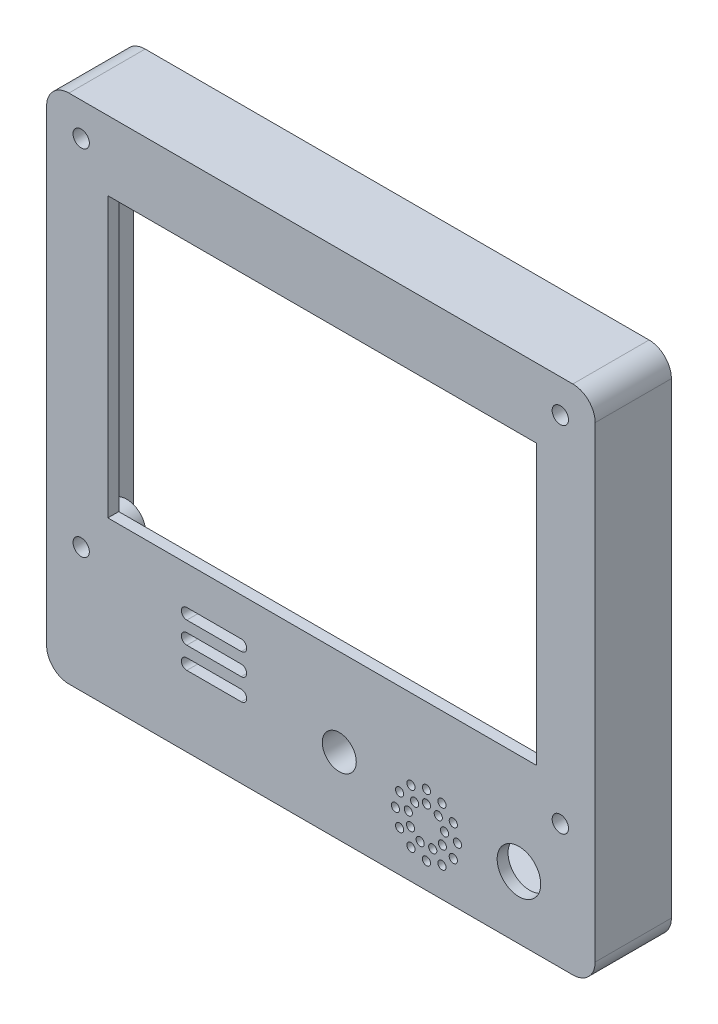
from build123d import *

# Parameters (mm, degrees)
SKETCH1_W           = 100.75
SKETCH1_H           = 94
BOSS_EXTRUDE1_DEPTH = 14
SHELL1_T            = -2
SKETCH2_R           = 3.5
SKETCH2_R_2         = 4
BOSS_EXTRUDE2_DEPTH = 6.3
SKETCH3_R           = 1.5
SKETCH3_R_2         = 4
SKETCH3_R_3         = 3.125
SKETCH3_R_4         = 0.75
SKETCH3_W           = 78.75
SKETCH3_H           = 51.25
CUT_EXTRUDE1_DEPTH  = 15
FILLET1_R           = 4.1


with BuildPart() as part:
    # Sketch1 → Boss-Extrude1 (new body)
    with BuildSketch(Plane.XY):
        Rectangle(SKETCH1_W, SKETCH1_H)
    extrude(amount=BOSS_EXTRUDE1_DEPTH)

    # Shell1
    shell1_openings = [part.faces().sort_by_distance(p)[0] for p in [
        (0, 0, 0),
    ]]
    offset(amount=SHELL1_T, openings=shell1_openings, kind=Kind.INTERSECTION)

    # Sketch2 → Boss-Extrude2 (add)
    with BuildSketch(Plane(origin=(0, 0, 12), x_dir=(-1, 0, 0), z_dir=(0, 0, -1))):
        with Locations((-43.975, 40.9)):
            Circle(SKETCH2_R)
        with Locations((-43.975, -24.1)):
            Circle(SKETCH2_R)
        with Locations((43.975, 40.9)):
            Circle(SKETCH2_R)
        with Locations((43.975, -24.1)):
            Circle(SKETCH2_R)
        with Locations((-3.375, -33)):
            Circle(SKETCH2_R_2)
    extrude(amount=BOSS_EXTRUDE2_DEPTH)

    # Sketch3 → Cut-Extrude1 (cut, through all)
    with BuildSketch(Plane.XY.offset(14)):
        with Locations((-44.025, 40.9)):
            Circle(SKETCH3_R)
        with Locations((43.975, 40.9)):
            Circle(SKETCH3_R)
        with Locations((43.975, -24.1)):
            Circle(SKETCH3_R)
        with Locations((-44.025, -24.1)):
            Circle(SKETCH3_R)
        with Locations((36.375, -35.5)):
            Circle(SKETCH3_R_2)
        with Locations((3.375, -33)):
            Circle(SKETCH3_R_3)
        with Locations((19.388263363, -33.242972513)):
            Circle(SKETCH3_R_4)
        with Locations((21.559750082, -34.033329043)):
            Circle(SKETCH3_R_4)
        with Locations((22.715174032, -36.034582029)):
            Circle(SKETCH3_R_4)
        with Locations((22.313899506, -38.310322957)):
            Circle(SKETCH3_R_4)
        with Locations((20.543687313, -39.795707355)):
            Circle(SKETCH3_R_4)
        with Locations((18.232839412, -39.795707355)):
            Circle(SKETCH3_R_4)
        with Locations((16.46262722, -38.310322957)):
            Circle(SKETCH3_R_4)
        with Locations((16.061352693, -36.034582029)):
            Circle(SKETCH3_R_4)
        with Locations((17.216776643, -34.033329043)):
            Circle(SKETCH3_R_4)
        with Locations((19.388263363, -30.927009025)):
            Circle(SKETCH3_R_4)
        with Locations((22.235361921, -31.689886784)):
            Circle(SKETCH3_R_4)
        with Locations((24.319582721, -33.774107583)):
            Circle(SKETCH3_R_4)
        with Locations((25.08246048, -36.621206142)):
            Circle(SKETCH3_R_4)
        with Locations((24.319582721, -39.468304701)):
            Circle(SKETCH3_R_4)
        with Locations((22.235361921, -41.5525255)):
            Circle(SKETCH3_R_4)
        with Locations((19.388263363, -42.31540326)):
            Circle(SKETCH3_R_4)
        with Locations((16.541164804, -41.5525255)):
            Circle(SKETCH3_R_4)
        with Locations((14.456944005, -39.468304701)):
            Circle(SKETCH3_R_4)
        with Locations((13.694066245, -36.621206142)):
            Circle(SKETCH3_R_4)
        with Locations((14.456944005, -33.774107583)):
            Circle(SKETCH3_R_4)
        with Locations((16.541164804, -31.689886784)):
            Circle(SKETCH3_R_4)
        with Locations((0.25, 8.625)):
            Rectangle(SKETCH3_W, SKETCH3_H)
        with BuildLine():
            Line((-24.625, -24), (-14.625, -24))
            ThreePointArc((-14.625, -24), (-13.625, -25), (-14.625, -26))
            Line((-14.625, -26), (-24.625, -26))
            ThreePointArc((-24.625, -26), (-25.625, -25), (-24.625, -24))
        make_face()
        with BuildLine():
            Line((-24.625, -28), (-14.625, -28))
            ThreePointArc((-14.625, -28), (-13.625, -29), (-14.625, -30))
            Line((-14.625, -30), (-24.625, -30))
            ThreePointArc((-24.625, -30), (-25.625, -29), (-24.625, -28))
        make_face()
        with BuildLine():
            Line((-24.625, -32), (-14.625, -32))
            ThreePointArc((-14.625, -32), (-13.625, -33), (-14.625, -34))
            Line((-14.625, -34), (-24.625, -34))
            ThreePointArc((-24.625, -34), (-25.625, -33), (-24.625, -32))
        make_face()
    extrude(amount=-CUT_EXTRUDE1_DEPTH, mode=Mode.SUBTRACT)

    # Fillet1
    fillet1_edges = [part.edges().sort_by_distance(p)[0] for p in [
        (50.375, -47, 7),
        (-50.375, -47, 7),
        (-50.375, 47, 7),
        (50.375, 47, 7),
    ]]
    fillet(fillet1_edges, radius=FILLET1_R)


solid = part.part
